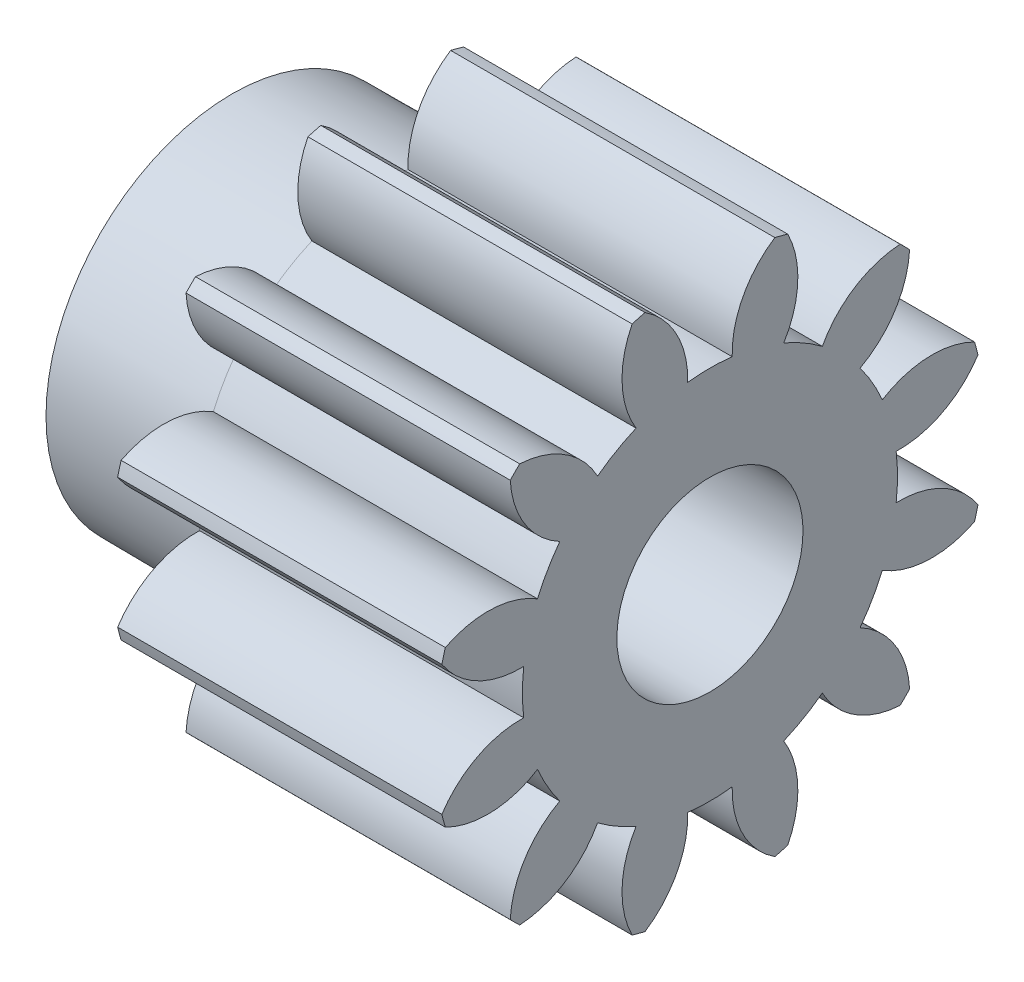
from build123d import *

# Parameters (mm, degrees)
BASPROSKE_W             = 12.7
BASPROSKE_H             = 8.89
TOOTHCUT_DEPTH          = 18.870484045
TEETHCUTS_COUNT         = 12
TEETHCUTS_ANGLE         = 330
BORSKE_R                = 3
BORE_DEPTH              = 50.8000508
SKETCH2_W               = 2.25
SKETCH2_H               = 17.280564042
CUT_EXTRUDE1_DEPTH      = 18.6238176
CUT_EXTRUDE1_DEPTH_BACK = 18.6238176


with BuildPart() as part:
    # BasProSke → Base-Revolve (revolve)
    with BuildSketch(Plane(origin=(0, 0, 0), x_dir=(1, 0, 0), z_dir=(0, 1, 0)), mode=Mode.PRIVATE) as base_revolve_sk:
        with Locations((6.35, 4.445)):
            Rectangle(BASPROSKE_W, BASPROSKE_H)
    revolve(base_revolve_sk.sketch.rotate(Axis((-10, 0, 0), (1, 0, 0)), 180), axis=Axis((-10, 0, 0), (1, 0, 0)))

    # TooCutSke → ToothCut (cut, through all)
    with BuildSketch(Plane(origin=(0, 0, 0), x_dir=(0, 0, -1), z_dir=(1, 0, 0))):
        with BuildLine():
            ThreePointArc((0.717076553, 6.002519826), (0, 6.0452), (-0.717076553, 6.002519826))
            ThreePointArc((-0.717076553, 6.002519826), (-1.069160545, 7.516029346), (-2.121611652, 8.659279483))
            ThreePointArc((-2.121611652, 8.659279483), (0, 8.9154), (2.121611652, 8.659279483))
            ThreePointArc((2.121611652, 8.659279483), (1.069160545, 7.516029346), (0.717076553, 6.002519826))
        make_face()
    toothcut = extrude(amount=TOOTHCUT_DEPTH, mode=Mode.SUBTRACT)

    # TeethCuts: ToothCut ×12 about axis
    teethcuts_axis = Axis((-10, 0, 0), (1, 0, 0))
    for i in range(1, TEETHCUTS_COUNT):
        add(toothcut.rotate(teethcuts_axis, i * TEETHCUTS_ANGLE / (TEETHCUTS_COUNT - 1)), mode=Mode.SUBTRACT)

    # BorSke → Bore (cut, symmetric)
    with BuildSketch(Plane(origin=(0, 0, 0), x_dir=(0, 0, -1), z_dir=(1, 0, 0))):
        with Locations(Location((0, 0, 0), (0, 0, 180))):
            Circle(BORSKE_R)
    extrude(amount=BORE_DEPTH, both=True, mode=Mode.SUBTRACT)

    # Sketch1 → Revolve1 (revolve)
    with BuildSketch(Plane.XY, mode=Mode.PRIVATE) as revolve1_sk:
        Polygon((0, -4), (-4.95, -4), (-4.95, -6), (0, -6.0452), align=None)
    revolve(revolve1_sk.sketch.rotate(Axis((0, 0, 0), (-1, 0, 0)), 270), axis=Axis((0, 0, 0), (-1, 0, 0)))

    # Sketch2 → Cut-Extrude1 (cut, two sides)
    with BuildSketch(Plane.XY) as cut_extrude1_sk:
        with Locations((11.575, 0)):
            Rectangle(SKETCH2_W, SKETCH2_H)
    extrude(amount=CUT_EXTRUDE1_DEPTH, mode=Mode.SUBTRACT)
    extrude(cut_extrude1_sk.sketch, amount=-CUT_EXTRUDE1_DEPTH_BACK, mode=Mode.SUBTRACT)


solid = part.part
